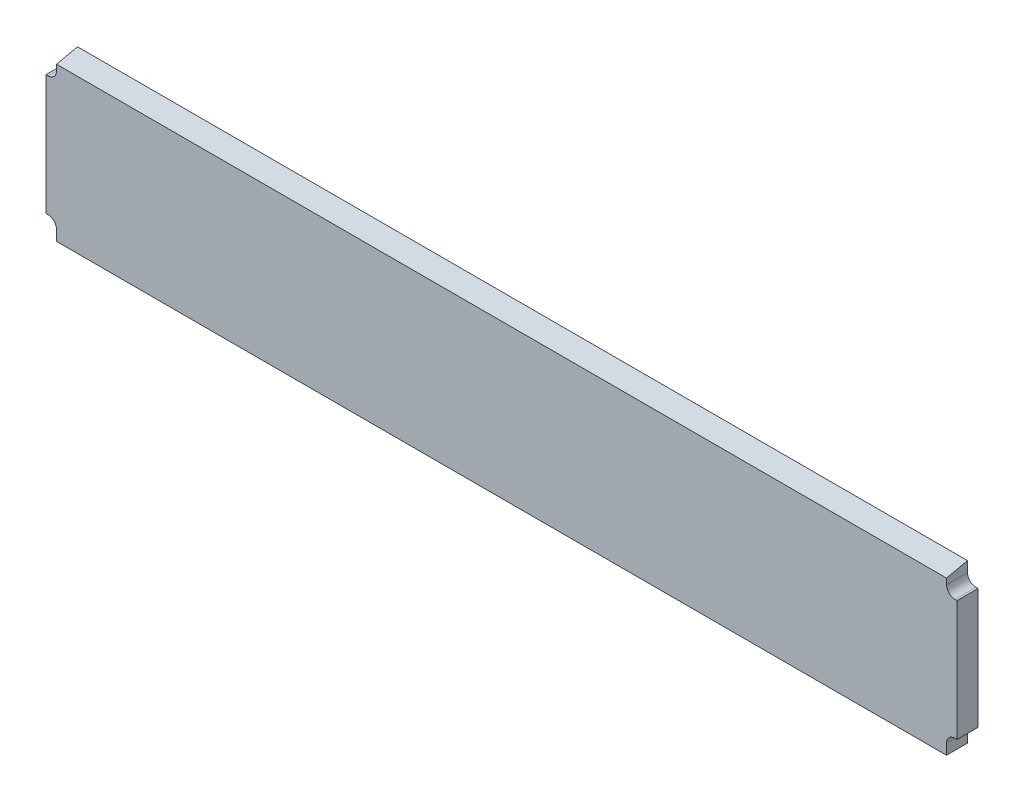
from build123d import *

# Parameters (mm, degrees)
BOSS_EXTRUDE1_DEPTH     = 15.875
FILLET1_R               = 6.35
CUT_EXTRUDE1_DEPTH      = 1
CUT_EXTRUDE1_DEPTH_BACK = 689.975


with BuildPart() as part:
    # Sketch1 → Boss-Extrude1 (new body)
    with BuildSketch(Plane.XY):
        Polygon((-336.55, -45.4914), (-336.55, -59.7789), (336.55, -59.7789), (336.55, -45.4914), (344.4875, -45.4914), (344.4875, 45.4914), (336.55, 45.4914), (336.55, 59.7789), (-336.55, 59.7789), (-336.55, 45.4914), (-344.4875, 45.4914), (-344.4875, -45.4914), align=None)
    extrude(amount=BOSS_EXTRUDE1_DEPTH)

    # Fillet1
    fillet1_edges = [part.edges().sort_by_distance(p)[0] for p in [
        (-336.55, 45.4914, 7.9375),
        (-336.55, -45.4914, 7.9375),
        (336.55, -45.4914, 7.9375),
        (336.55, 45.4914, 7.9375),
    ]]
    fillet(fillet1_edges, radius=FILLET1_R)

    # Sketch2 → Cut-Extrude1 (cut, two sides)
    with BuildSketch(Plane(origin=(344.4875, 0, 0), x_dir=(0, 0, -1), z_dir=(1, 0, 0))) as cut_extrude1_sk:
        Polygon((0, 59.7789), (-15.875, 56.259497231), (-15.875, 59.7789), align=None)
    extrude(amount=CUT_EXTRUDE1_DEPTH, mode=Mode.SUBTRACT)
    extrude(cut_extrude1_sk.sketch, amount=-CUT_EXTRUDE1_DEPTH_BACK, mode=Mode.SUBTRACT)


solid = part.part
